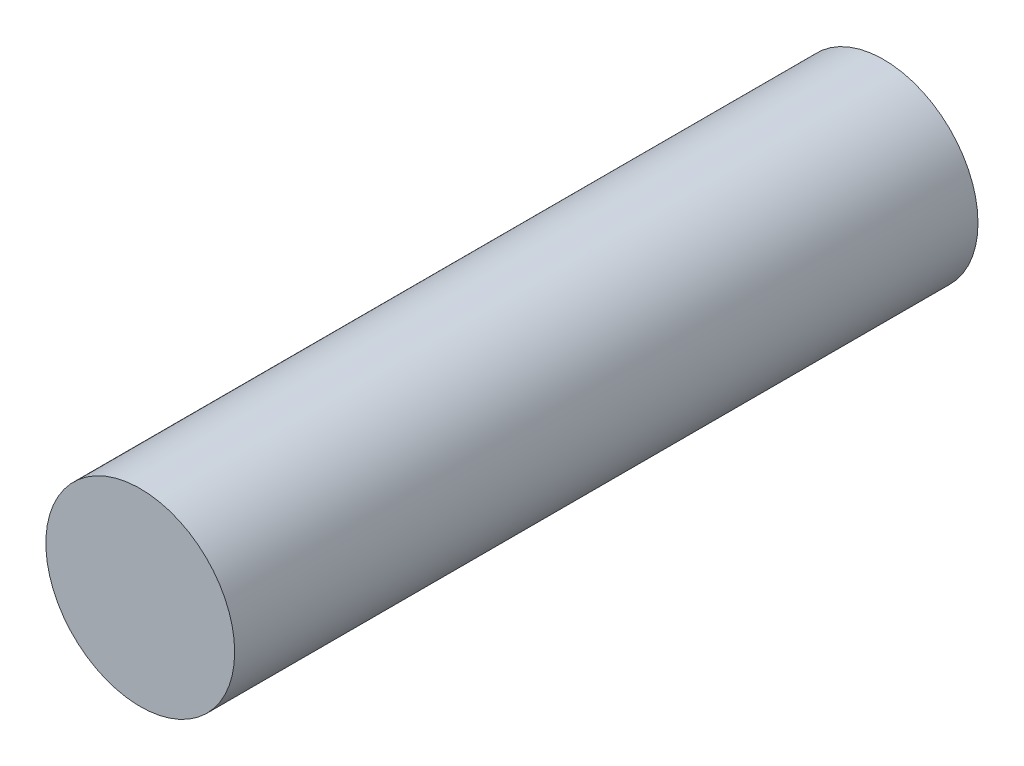
from build123d import *

# Parameters (mm, degrees)
SKETCH1_R           = 6.35
BOSS_EXTRUDE1_DEPTH = 50


with BuildPart() as part:
    # Sketch1 → Boss-Extrude1 (new body)
    with BuildSketch(Plane.XY):
        Circle(SKETCH1_R)
    extrude(amount=BOSS_EXTRUDE1_DEPTH)


solid = part.part
